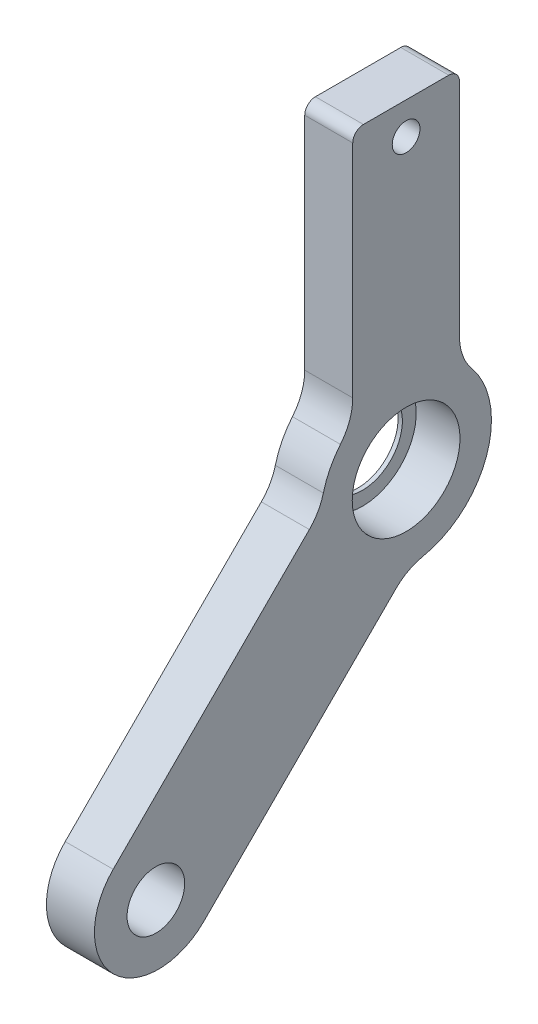
from build123d import *

# Parameters (mm, degrees)
SKETCH_1_R          = 3.75
SKETCH_1_R_2        = 1.3
SKETCH_1_R_3        = 2.7
EXTRUDE_1_DEPTH     = 2.25
SKETCH_7_R          = 5.05
CUT_EXTRUDE_4_DEPTH = 4.1


with BuildPart() as part:
    # 草图1 → 凸台-拉伸1 (new body, symmetric)
    with BuildSketch(Plane.ZY):
        with BuildLine():
            Line((-4, 30), (4, 30))
            ThreePointArc((4, 30), (4.707106781, 29.707106781), (5, 29))
            Line((5, 29), (5, 8.306623863))
            ThreePointArc((5, 8.306623863), (5.297300284, 6.608208312), (6.153846154, 5.111768531))
            ThreePointArc((6.153846154, 5.111768531), (7.130688706, 3.626744901), (7.755507367, 1.962678138))
            ThreePointArc((7.755507367, 1.962678138), (8.255259703, 0.719581246), (9.067165566, -0.346181931))
            Line((9.067165566, -0.346181931), (27.451942184, -18.730958549))
            ThreePointArc((27.451942184, -18.730958549), (27.451942184, -27.216239924), (18.96666081, -27.216239924))
            Line((18.96666081, -27.216239924), (0.956494183, -9.206073297))
            ThreePointArc((0.956494183, -9.206073297), (-0.214644447, -8.335970475), (-1.587101368, -7.840989048))
            ThreePointArc((-1.587101368, -7.840989048), (-7.544802804, -2.660065909), (-6.153846154, 5.111768531))
            ThreePointArc((-6.153846154, 5.111768531), (-5.297300284, 6.608208312), (-5, 8.306623863))
            Line((-5, 8.306623863), (-5, 29))
            ThreePointArc((-5, 29), (-4.707106781, 29.707106781), (-4, 30))
        make_face()
        Circle(SKETCH_1_R, mode=Mode.SUBTRACT)
        with Locations((0, 27)):
            Circle(SKETCH_1_R_2, mode=Mode.SUBTRACT)
        with Locations((23.452077304, -23.216375043)):
            Circle(SKETCH_1_R_3, mode=Mode.SUBTRACT)
    extrude(amount=EXTRUDE_1_DEPTH, both=True)

    # 草图7 → 切除-拉伸4 (cut)
    with BuildSketch(Plane.ZY.offset(-2.25)):
        Circle(SKETCH_7_R)
    extrude(amount=CUT_EXTRUDE_4_DEPTH, mode=Mode.SUBTRACT)


solid = part.part
